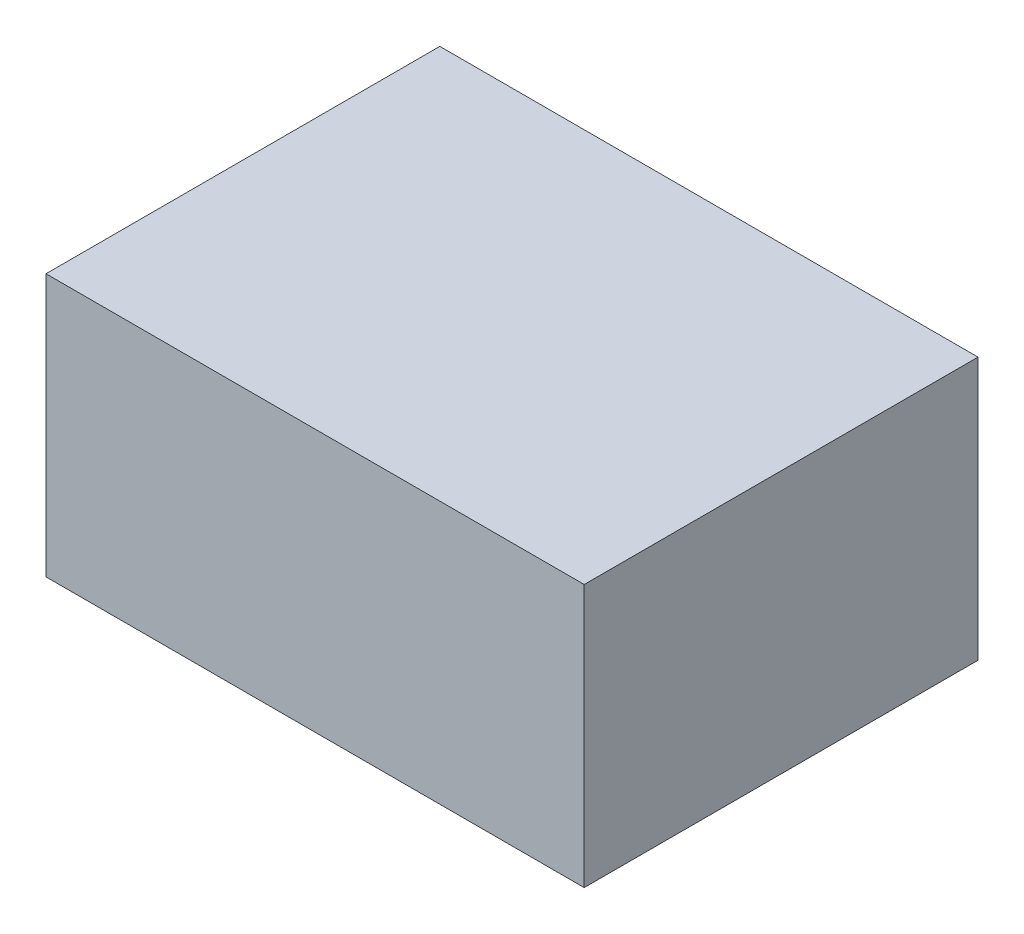
from build123d import *

# Parameters (mm, degrees)
CROQUIS1_W              = 41
CROQUIS1_H              = 20
SALIENTE_EXTRUIR1_DEPTH = 30


with BuildPart() as part:
    # Croquis1 → Saliente-Extruir1 (new body)
    with BuildSketch(Plane.XY):
        Rectangle(CROQUIS1_W, CROQUIS1_H)
    extrude(amount=SALIENTE_EXTRUIR1_DEPTH)


solid = part.part
